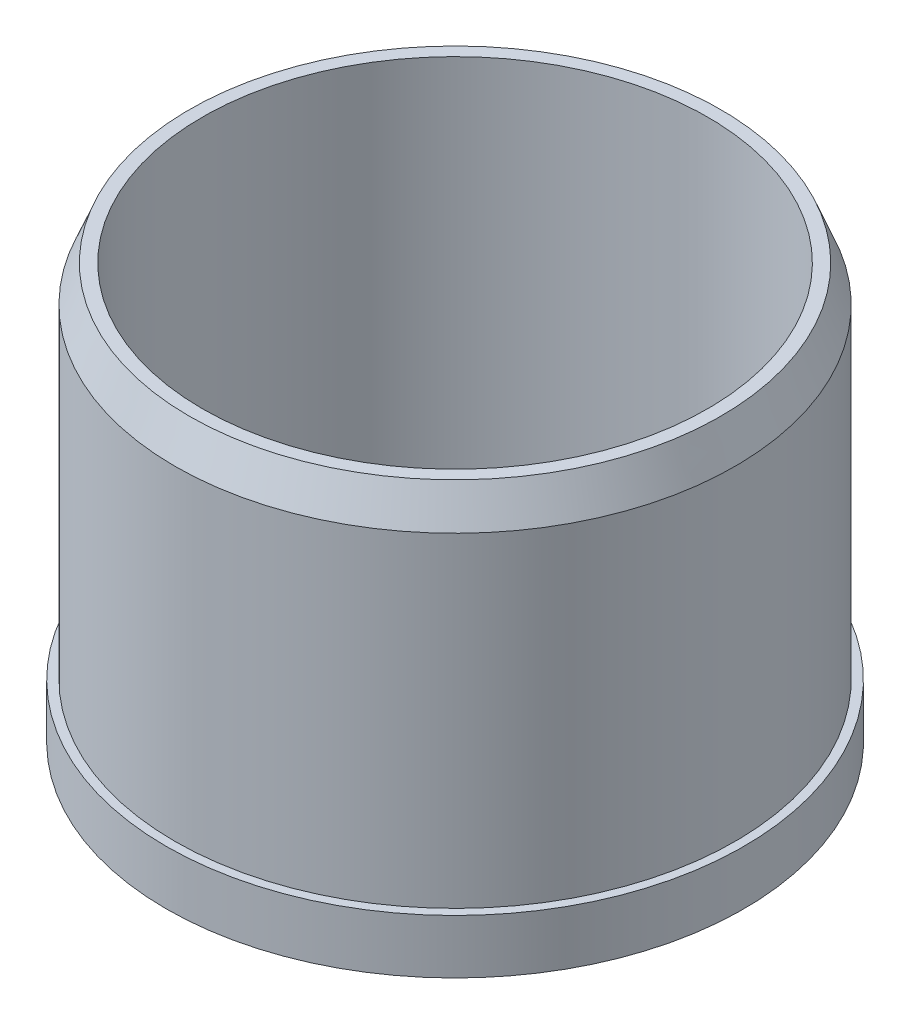
from build123d import *

# Parameters (mm, degrees)
SKETCH1_R           = 50.8
SKETCH1_R_2         = 12.7
BOSS_EXTRUDE1_DEPTH = 9.525
SKETCH2_R           = 49.276
SKETCH2_R_2         = 44.45
BOSS_EXTRUDE2_DEPTH = 63.5
SKETCH3_R           = 12.7
BOSS_EXTRUDE3_DEPTH = 15.875
CHAMFER1_SIZE       = 6.35
CHAMFER1_SIZE2      = 2.54
SKETCH4_R           = 12.7
BOSS_EXTRUDE4_DEPTH = 6.35
FILLET1_R           = 2.54


with BuildPart() as part:
    # Sketch1 → Boss-Extrude1 (new body)
    with BuildSketch(Plane(origin=(0, 0, 0), x_dir=(1, 0, 0), z_dir=(0, 1, 0))):
        Circle(SKETCH1_R)
        with Locations((-16.795963584, -23.117660614)):
            Circle(SKETCH1_R_2, mode=Mode.SUBTRACT)
        with Locations((16.795963584, -23.117660614)):
            Circle(SKETCH1_R_2, mode=Mode.SUBTRACT)
        with BuildLine():
            Line((9.6, -2.5), (6.64529909, -2.5))
            ThreePointArc((6.64529909, -2.5), (-7.1, 0), (6.64529909, 2.5))
            Line((6.64529909, 2.5), (9.6, 2.5))
            Line((9.6, 2.5), (9.6, -2.5))
        make_face(mode=Mode.SUBTRACT)
        with Locations((-27.176439953, 8.830160614)):
            Circle(SKETCH1_R_2, mode=Mode.SUBTRACT)
        with BuildLine():
            ThreePointArc((0, 15.875), (-12.7, 28.575), (0, 41.275))
            ThreePointArc((0, 41.275), (12.7, 28.575), (0, 15.875))
        make_face(mode=Mode.SUBTRACT)
        with Locations((27.176439953, 8.830160614)):
            Circle(SKETCH1_R_2, mode=Mode.SUBTRACT)
    extrude(amount=BOSS_EXTRUDE1_DEPTH)

    # Sketch2 → Boss-Extrude2 (add)
    with BuildSketch(Plane(origin=(0, 9.525, 0), x_dir=(1, 0, 0), z_dir=(0, 1, 0))):
        Circle(SKETCH2_R)
        Circle(SKETCH2_R_2, mode=Mode.SUBTRACT)
    extrude(amount=BOSS_EXTRUDE2_DEPTH)

    # Sketch3 → Boss-Extrude3 (add)
    with BuildSketch(Plane(origin=(0, 9.525, 0), x_dir=(1, 0, 0), z_dir=(0, 1, 0))):
        Circle(SKETCH3_R)
        with BuildLine():
            Line((9.6, -2.5), (6.64529909, -2.5))
            ThreePointArc((6.64529909, -2.5), (-7.1, 0), (6.64529909, 2.5))
            Line((6.64529909, 2.5), (9.6, 2.5))
            Line((9.6, 2.5), (9.6, -2.5))
        make_face(mode=Mode.SUBTRACT)
    extrude(amount=BOSS_EXTRUDE3_DEPTH)

    # Chamfer1
    chamfer1_edges = [part.edges().sort_by_distance(p)[0] for p in [
        (-49.276, 73.025, 0),
    ]]
    chamfer1_side = [part.faces().sort_by_distance(p)[0] for p in [
        (-49.276, 41.275, 0),
    ]]
    chamfer(chamfer1_edges, length=CHAMFER1_SIZE, length2=CHAMFER1_SIZE2, reference=chamfer1_side[0])

    # Sketch4 → Boss-Extrude4 (add)
    with BuildSketch(Plane(origin=(0, 25.4, 0), x_dir=(1, 0, 0), z_dir=(0, 1, 0))):
        Circle(SKETCH4_R)
    extrude(amount=BOSS_EXTRUDE4_DEPTH)

    # Fillet1
    fillet1_edges = [part.edges().sort_by_distance(p)[0] for p in [
        (-12.7, 31.75, 0),
    ]]
    fillet(fillet1_edges, radius=FILLET1_R)


solid = part.part
